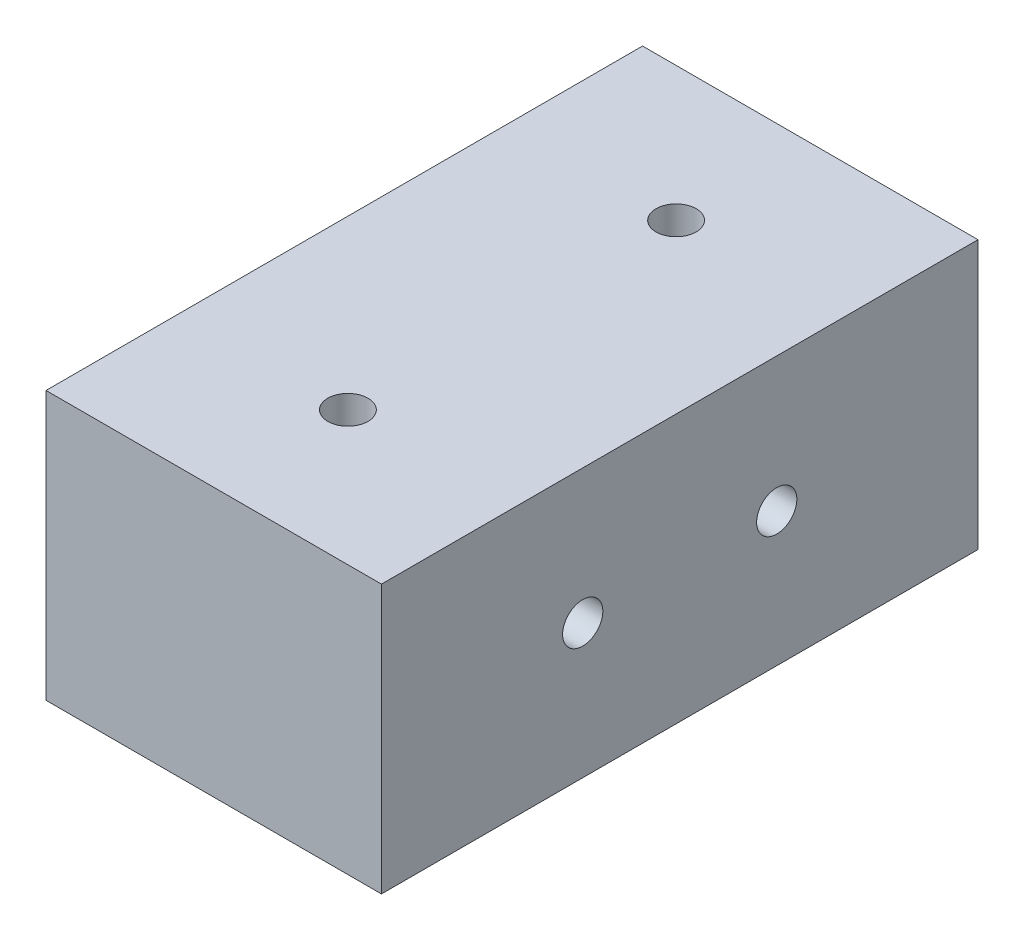
from build123d import *

# Parameters (mm, degrees)
CROQUIS2_W              = 44.460320701
CROQUIS2_H              = 20
SALIENTE_EXTRUIR2_DEPTH = 25
CROQUIS3_R              = 1.5
CORTAR_EXTRUIR1_DEPTH   = 21
CROQUIS4_R              = 1.5
CORTAR_EXTRUIR2_DEPTH   = 50


with BuildPart() as part:
    # Croquis2 → Saliente-Extruir2 (new body)
    with BuildSketch(Plane(origin=(0, 0, 0), x_dir=(0, 0, -1), z_dir=(1, 0, 0))):
        with Locations((-22.230160351, -10)):
            Rectangle(CROQUIS2_W, CROQUIS2_H)
    extrude(amount=SALIENTE_EXTRUIR2_DEPTH)

    # Croquis3 → Cortar-Extruir1 (cut, through all)
    with BuildSketch(Plane.XZ.offset(20)):
        with Locations((12.5, 10)):
            Circle(CROQUIS3_R)
        with Locations((12.5, 34.460320701)):
            Circle(CROQUIS3_R)
    extrude(amount=-CORTAR_EXTRUIR1_DEPTH, mode=Mode.SUBTRACT)

    # Croquis4 → Cortar-Extruir2 (cut)
    with BuildSketch(Plane(origin=(25, 0, 0), x_dir=(0, 0, -1), z_dir=(1, 0, 0))):
        with Locations((-29.460320701, -10)):
            Circle(CROQUIS4_R)
        with Locations((-15, -10)):
            Circle(CROQUIS4_R)
    extrude(amount=-CORTAR_EXTRUIR2_DEPTH, mode=Mode.SUBTRACT)


solid = part.part
